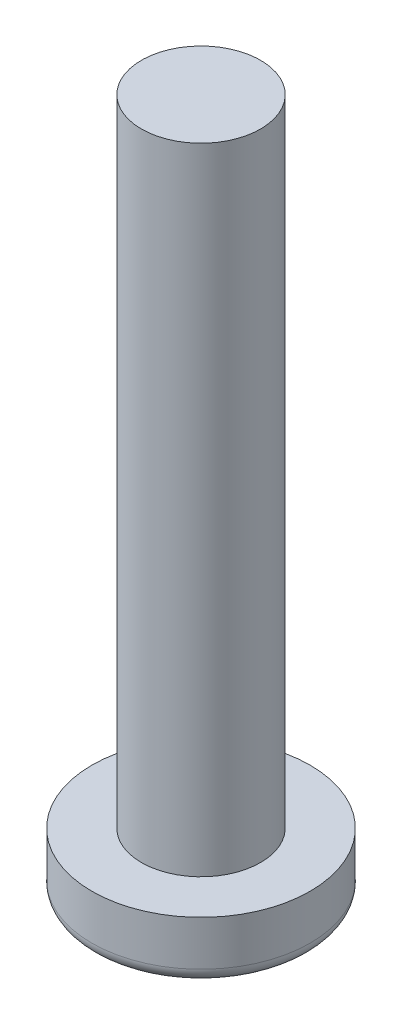
from build123d import *

# Parameters (mm, degrees)
SKETCH_1_W      = 2.75
SKETCH_1_H      = 1.5
SKETCH_2_R      = 1.5
EXTRUDE_1_DEPTH = 16
FILLET_1_R      = 0.367346939


with BuildPart() as part:
    # 草图1 → 旋转1 (revolve)
    with BuildSketch(Plane.XY.offset(15)):
        with Locations((1.375, 0.75)):
            Rectangle(SKETCH_1_W, SKETCH_1_H)
    revolve(axis=Axis((0, 1.5, 15), (0, -1, 0)))

    # 草图2 → 凸台-拉伸1 (add)
    with BuildSketch(Plane(origin=(0, 1.5, 0), x_dir=(-1, 0, 0), z_dir=(0, 1, 0))):
        with Locations((0, 15)):
            Circle(SKETCH_2_R)
    extrude(amount=EXTRUDE_1_DEPTH)

    # 圆角1
    fillet_1_edges = [part.edges().sort_by_distance(p)[0] for p in [
        (-2.75, 0, 15),
    ]]
    fillet(fillet_1_edges, radius=FILLET_1_R)


solid = part.part
